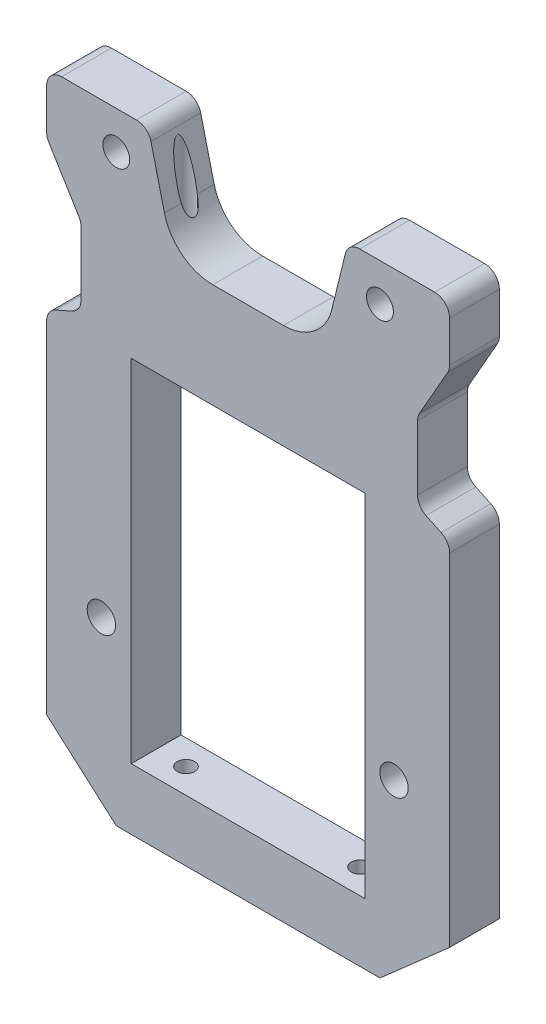
from build123d import *

# Parameters (mm, degrees)
SKETCH_2_W          = 46.980294199
SKETCH_2_H          = 70.564750697
SKETCH_2_R          = 2.7
SKETCH_2_R_2        = 2.85
EXTRUDE_1_DEPTH     = 10
SKETCH_4_R          = 1.75
CUT_EXTRUDE_1_DEPTH = 125.878321509
FILLET_1_R          = 3


with BuildPart() as part:
    # Эскиз2 → Бобышка-Вытянуть1 (new body)
    with BuildSketch(Plane.XY):
        with BuildLine():
            Line((20.393728877, 100.097628386), (0, 100.097628386))
            Line((0, 100.097628386), (0, 88.097628386))
            Line((0, 88.097628386), (6.895756981, 76.811268447))
            Line((6.895756981, 76.811268447), (6.895756981, 61.147856497))
            Line((6.895756981, 61.147856497), (0, 58.097628386))
            Line((0, 58.097628386), (0, -12.467122311))
            Line((0, -12.467122311), (14, -24.780693123))
            Line((14, -24.780693123), (66.980294199, -24.780693123))
            Line((66.980294199, -24.780693123), (80.980294199, -12.467122311))
            Line((80.980294199, -12.467122311), (80.980294199, 58.097628386))
            Line((80.980294199, 58.097628386), (74.539362977, 61.147856497))
            Line((74.539362977, 61.147856497), (74.539362977, 76.811268447))
            Line((74.539362977, 76.811268447), (80.980294199, 88.097628386))
            Line((80.980294199, 88.097628386), (80.980294199, 100.097628386))
            Line((80.980294199, 100.097628386), (60.586565322, 100.097628386))
            Line((60.586565322, 100.097628386), (57.310276596, 86.719014111))
            ThreePointArc((57.310276596, 86.719014111), (53.770366565, 81.230413417), (47.597285598, 79.097628386))
            Line((47.597285598, 79.097628386), (33.383008601, 79.097628386))
            ThreePointArc((33.383008601, 79.097628386), (27.209927634, 81.230413417), (23.670017603, 86.719014111))
            Line((23.670017603, 86.719014111), (20.393728877, 100.097628386))
        make_face()
        with Locations((40.4901471, 22.815253037)):
            Rectangle(SKETCH_2_W, SKETCH_2_H, mode=Mode.SUBTRACT)
        with Locations((14, 92.5)):
            Circle(SKETCH_2_R, mode=Mode.SUBTRACT)
        with Locations((66.980294199, 92.5)):
            Circle(SKETCH_2_R, mode=Mode.SUBTRACT)
        with Locations((11, 10)):
            Circle(SKETCH_2_R_2, mode=Mode.SUBTRACT)
        with Locations((69.808458797, 11.064595212)):
            Circle(SKETCH_2_R_2, mode=Mode.SUBTRACT)
    extrude(amount=EXTRUDE_1_DEPTH)

    # Эскиз4 → Вырез-Вытянуть1 (cut, through all)
    with BuildSketch(Plane(origin=(0, 100.097628386, 0), x_dir=(1, 0, 0), z_dir=(0, 1, 0))):
        with Locations((23, -5)):
            Circle(SKETCH_4_R)
        with Locations((57.980294199, -5)):
            Circle(SKETCH_4_R)
    extrude(amount=-CUT_EXTRUDE_1_DEPTH, mode=Mode.SUBTRACT)

    # Скругление1
    fillet_1_edges = [part.edges().sort_by_distance(p)[0] for p in [
        (60.586565322, 100.097628386, 5),
        (80.980294199, 100.097628386, 5),
        (80.980294199, 88.097628386, 5),
        (74.539362977, 76.811268447, 5),
        (74.539362977, 61.147856497, 5),
        (80.980294199, 58.097628386, 5),
        (0, 58.097628386, 5),
        (6.895756981, 61.147856497, 5),
        (6.895756981, 76.811268447, 5),
        (0, 88.097628386, 5),
        (0, 100.097628386, 5),
        (20.393728877, 100.097628386, 5),
    ]]
    fillet(fillet_1_edges, radius=FILLET_1_R)


solid = part.part
